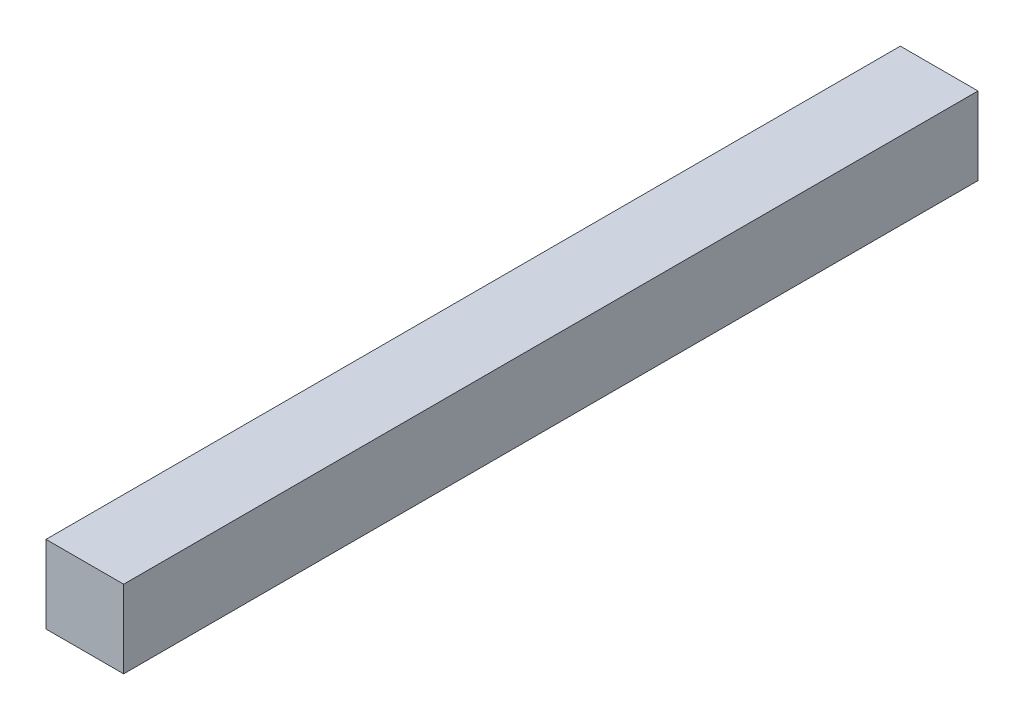
from build123d import *

# Parameters (mm, degrees)
SKETCH1_W           = 25.4
SKETCH1_H           = 25.4
BOSS_EXTRUDE1_DEPTH = 279.4


with BuildPart() as part:
    # Sketch1 → Boss-Extrude1 (new body)
    with BuildSketch(Plane.XY):
        with Locations((-12.7, 12.7)):
            Rectangle(SKETCH1_W, SKETCH1_H)
    extrude(amount=BOSS_EXTRUDE1_DEPTH)


solid = part.part
